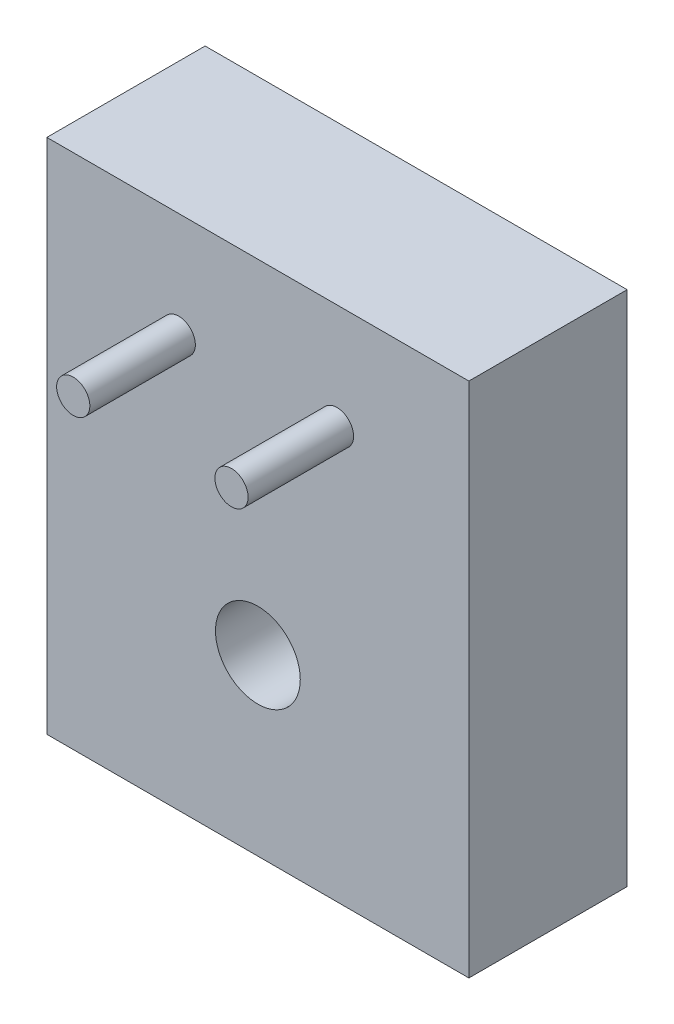
from build123d import *

# Parameters (mm, degrees)
SKETCH1_W           = 25.4
SKETCH1_H           = 31.115
SKETCH1_R           = 2.5527
BOSS_EXTRUDE2_DEPTH = 9.525
SKETCH2_R           = 1
BOSS_EXTRUDE3_DEPTH = 6.35


with BuildPart() as part:
    # Sketch1 → Boss-Extrude2 (new body)
    with BuildSketch(Plane.XY):
        with Locations((12.7, -15.5575)):
            Rectangle(SKETCH1_W, SKETCH1_H)
        with Locations((12.7, -20.6375)):
            Circle(SKETCH1_R, mode=Mode.SUBTRACT)
    extrude(amount=BOSS_EXTRUDE2_DEPTH)

    # Sketch2 → Boss-Extrude3 (add)
    with BuildSketch(Plane.XY.offset(9.525)):
        with Locations((7.9375, -6.35)):
            Circle(SKETCH2_R)
        with Locations((17.4625, -6.35)):
            Circle(SKETCH2_R)
    extrude(amount=BOSS_EXTRUDE3_DEPTH)


solid = part.part
